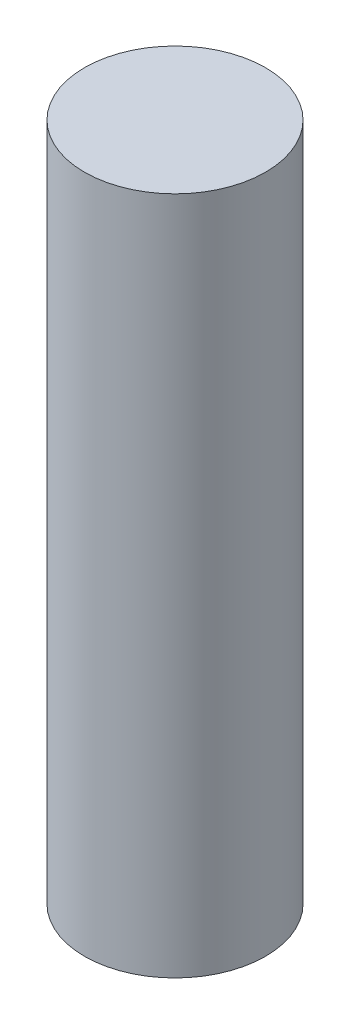
from build123d import *

# Parameters (mm, degrees)
ESQUISSE1_R        = 2
BOSS_EXTRU_1_DEPTH = 15


with BuildPart() as part:
    # Esquisse1 → Boss.-Extru.1 (new body)
    with BuildSketch(Plane(origin=(0, 0, 0), x_dir=(1, 0, 0), z_dir=(0, 1, 0))):
        Circle(ESQUISSE1_R)
    extrude(amount=BOSS_EXTRU_1_DEPTH)


solid = part.part
